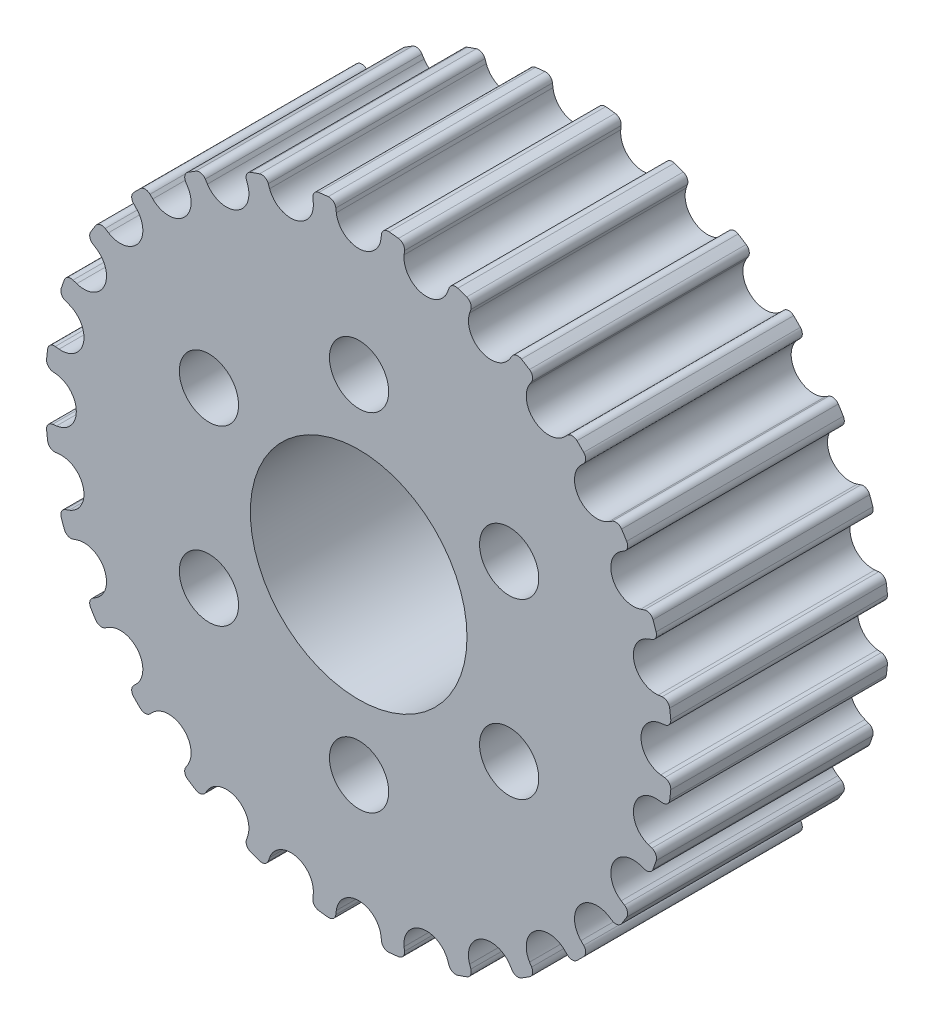
from build123d import *

# Parameters (mm, degrees)
SKETCH_1_R              = 7.5
EXTRUDE_1_DEPTH         = 15
HOLE_WIZARD_4_1_4_1_1_D = 4.1


with BuildPart() as part:
    # 草图1 → 凸台-拉伸1 (new body)
    with BuildSketch(Plane.XY):
        with BuildLine():
            Line((1.554033471, 21.184411781), (1.521048557, 20.915771216))
            ThreePointArc((1.521048557, 20.915771216), (-0.027323439, 19.545887392), (-1.575695436, 20.915771216))
            Line((-1.575695436, 20.915771216), (-1.608680349, 21.184411781))
            ThreePointArc((-1.608680349, 21.184411781), (-1.784864491, 21.500423691), (-2.131632272, 21.603653945))
            ThreePointArc((-2.131632272, 21.603653945), (-2.457848286, 21.569392044), (-2.783509374, 21.530205035))
            ThreePointArc((-2.783509374, 21.530205035), (-3.09861207, 21.352399889), (-3.200059642, 21.005106398))
            Line((-3.200059642, 21.005106398), (-3.172439406, 20.735861379))
            ThreePointArc((-3.172439406, 20.735861379), (-4.377162656, 19.055778219), (-6.191541562, 20.046771013))
            Line((-6.191541562, 20.046771013), (-6.283477625, 20.301336364))
            ThreePointArc((-6.283477625, 20.301336364), (-6.525563727, 20.570220536), (-6.886608208, 20.593699501))
            ThreePointArc((-6.886608208, 20.593699501), (-7.197021316, 20.487706726), (-7.505797471, 20.377035808))
            ThreePointArc((-7.505797471, 20.377035808), (-7.773434517, 20.133571662), (-7.795058515, 19.772411335))
            Line((-7.795058515, 19.772411335), (-7.708218122, 19.516062931))
            ThreePointArc((-7.708218122, 19.516062931), (-8.508882771, 17.610026822), (-10.498288052, 18.172436068))
            Line((-10.498288052, 18.172436068), (-10.644565205, 18.400161236))
            ThreePointArc((-10.644565205, 18.400161236), (-10.940414061, 18.608434695), (-11.297630964, 18.550985038))
            ThreePointArc((-11.297630964, 18.550985038), (-11.576675756, 18.378576309), (-11.853083652, 18.201970983))
            ThreePointArc((-11.853083652, 18.201970983), (-12.059834609, 17.905056146), (-12.000550715, 17.54813907))
            Line((-12.000550715, 17.54813907), (-11.858844707, 17.317541662))
            ThreePointArc((-11.858844707, 17.317541662), (-12.215302086, 15.281129211), (-14.279976653, 15.386753363))
            Line((-14.279976653, 15.386753363), (-14.47325995, 15.576219257))
            ThreePointArc((-14.47325995, 15.576219257), (-14.808036462, 15.713438301), (-15.14351344, 15.577940788))
            ThreePointArc((-15.14351344, 15.577940788), (-15.377197445, 15.347761398), (-15.607376836, 15.114077393))
            ThreePointArc((-15.607376836, 15.114077393), (-15.742874348, 14.778600415), (-15.605655304, 14.443823903))
            Line((-15.605655304, 14.443823903), (-15.41618941, 14.250540606))
            ThreePointArc((-15.41618941, 14.250540606), (-15.310565258, 12.185866039), (-17.346977709, 11.829408659))
            Line((-17.346977709, 11.829408659), (-17.577575117, 11.971114668))
            ThreePointArc((-17.577575117, 11.971114668), (-17.934492193, 12.030398562), (-18.23140703, 11.823647605))
            ThreePointArc((-18.23140703, 11.823647605), (-18.408012356, 11.547239709), (-18.580421086, 11.268194917))
            ThreePointArc((-18.580421086, 11.268194917), (-18.637870742, 10.910978014), (-18.429597284, 10.615129158))
            Line((-18.429597284, 10.615129158), (-18.201872116, 10.468852005))
            ThreePointArc((-18.201872116, 10.468852005), (-17.639462869, 8.479446724), (-19.545498979, 7.678782075))
            Line((-19.545498979, 7.678782075), (-19.801847382, 7.765622467))
            ThreePointArc((-19.801847382, 7.765622467), (-20.163007709, 7.74399847), (-20.406471855, 7.476361423))
            ThreePointArc((-20.406471855, 7.476361423), (-20.517142773, 7.167585269), (-20.623135549, 6.857172161))
            ThreePointArc((-20.623135549, 6.857172161), (-20.599656583, 6.49612768), (-20.330772412, 6.254041577))
            Line((-20.330772412, 6.254041577), (-20.07620706, 6.162105515))
            ThreePointArc((-20.07620706, 6.162105515), (-19.085214266, 4.347726609), (-20.765297426, 3.143003359))
            Line((-20.765297426, 3.143003359), (-21.034542445, 3.170623595))
            ThreePointArc((-21.034542445, 3.170623595), (-21.381835936, 3.069176023), (-21.559641082, 2.754073327))
            ThreePointArc((-21.559641082, 2.754073327), (-21.598828091, 2.428412239), (-21.633089992, 2.102196225))
            ThreePointArc((-21.633089992, 2.102196225), (-21.529859738, 1.755428444), (-21.213847828, 1.579244302))
            Line((-21.213847828, 1.579244302), (-20.945207263, 1.546259388))
            ThreePointArc((-20.945207263, 1.546259388), (-19.575323439, -0.002112608), (-20.945207263, -1.550484605))
            Line((-20.945207263, -1.550484605), (-21.213847828, -1.583469519))
            ThreePointArc((-21.213847828, -1.583469519), (-21.529859738, -1.75965366), (-21.633089992, -2.106421441))
            ThreePointArc((-21.633089992, -2.106421441), (-21.598828091, -2.432637455), (-21.559641082, -2.758298543))
            ThreePointArc((-21.559641082, -2.758298543), (-21.381835936, -3.073401239), (-21.034542445, -3.174848812))
            Line((-21.034542445, -3.174848812), (-20.765297426, -3.147228575))
            ThreePointArc((-20.765297426, -3.147228575), (-19.085214266, -4.351951825), (-20.07620706, -6.166330731))
            Line((-20.07620706, -6.166330731), (-20.330772412, -6.258266794))
            ThreePointArc((-20.330772412, -6.258266794), (-20.599656583, -6.500352897), (-20.623135549, -6.861397377))
            ThreePointArc((-20.623135549, -6.861397377), (-20.517142773, -7.171810485), (-20.406471855, -7.48058664))
            ThreePointArc((-20.406471855, -7.48058664), (-20.163007709, -7.748223686), (-19.801847382, -7.769847684))
            Line((-19.801847382, -7.769847684), (-19.545498979, -7.683007291))
            ThreePointArc((-19.545498979, -7.683007291), (-17.639462869, -8.48367194), (-18.201872116, -10.473077221))
            Line((-18.201872116, -10.473077221), (-18.429597284, -10.619354374))
            ThreePointArc((-18.429597284, -10.619354374), (-18.637870742, -10.91520323), (-18.580421086, -11.272420133))
            ThreePointArc((-18.580421086, -11.272420133), (-18.408012356, -11.551464925), (-18.23140703, -11.827872821))
            ThreePointArc((-18.23140703, -11.827872821), (-17.934492193, -12.034623778), (-17.577575117, -11.975339884))
            Line((-17.577575117, -11.975339884), (-17.346977709, -11.833633876))
            ThreePointArc((-17.346977709, -11.833633876), (-15.310565258, -12.190091255), (-15.41618941, -14.254765823))
            Line((-15.41618941, -14.254765823), (-15.605655304, -14.448049119))
            ThreePointArc((-15.605655304, -14.448049119), (-15.742874348, -14.782825631), (-15.607376836, -15.11830261))
            ThreePointArc((-15.607376836, -15.11830261), (-15.377197445, -15.351986614), (-15.14351344, -15.582166005))
            ThreePointArc((-15.14351344, -15.582166005), (-14.808036462, -15.717663517), (-14.47325995, -15.580444473))
            Line((-14.47325995, -15.580444473), (-14.279976653, -15.390978579))
            ThreePointArc((-14.279976653, -15.390978579), (-12.215302086, -15.285354427), (-11.858844707, -17.321766878))
            Line((-11.858844707, -17.321766878), (-12.000550715, -17.552364287))
            ThreePointArc((-12.000550715, -17.552364287), (-12.059834609, -17.909281362), (-11.853083652, -18.206196199))
            ThreePointArc((-11.853083652, -18.206196199), (-11.576675756, -18.382801525), (-11.297630964, -18.555210255))
            ThreePointArc((-11.297630964, -18.555210255), (-10.940414061, -18.612659911), (-10.644565205, -18.404386453))
            Line((-10.644565205, -18.404386453), (-10.498288052, -18.176661285))
            ThreePointArc((-10.498288052, -18.176661285), (-8.508882771, -17.614252038), (-7.708218122, -19.520288148))
            Line((-7.708218122, -19.520288148), (-7.795058515, -19.776636551))
            ThreePointArc((-7.795058515, -19.776636551), (-7.773434517, -20.137796878), (-7.505797471, -20.381261024))
            ThreePointArc((-7.505797471, -20.381261024), (-7.197021316, -20.491931943), (-6.886608208, -20.597924718))
            ThreePointArc((-6.886608208, -20.597924718), (-6.525563727, -20.574445752), (-6.283477625, -20.305561581))
            Line((-6.283477625, -20.305561581), (-6.191541562, -20.050996229))
            ThreePointArc((-6.191541562, -20.050996229), (-4.377162656, -19.060003436), (-3.172439406, -20.740086595))
            Line((-3.172439406, -20.740086595), (-3.200059642, -21.009331614))
            ThreePointArc((-3.200059642, -21.009331614), (-3.09861207, -21.356625105), (-2.783509374, -21.534430251))
            ThreePointArc((-2.783509374, -21.534430251), (-2.457848286, -21.573617261), (-2.131632272, -21.607879161))
            ThreePointArc((-2.131632272, -21.607879161), (-1.784864491, -21.504648907), (-1.608680349, -21.188636997))
            Line((-1.608680349, -21.188636997), (-1.575695436, -20.919996432))
            ThreePointArc((-1.575695436, -20.919996432), (-0.027323439, -19.550112608), (1.521048557, -20.919996432))
            Line((1.521048557, -20.919996432), (1.554033471, -21.188636997))
            ThreePointArc((1.554033471, -21.188636997), (1.730217613, -21.504648907), (2.076985394, -21.607879161))
            ThreePointArc((2.076985394, -21.607879161), (2.403201408, -21.573617261), (2.728862496, -21.534430251))
            ThreePointArc((2.728862496, -21.534430251), (3.043965192, -21.356625105), (3.145412764, -21.009331614))
            Line((3.145412764, -21.009331614), (3.117792528, -20.740086595))
            ThreePointArc((3.117792528, -20.740086595), (4.322515778, -19.060003436), (6.136894684, -20.050996229))
            Line((6.136894684, -20.050996229), (6.228830746, -20.305561581))
            ThreePointArc((6.228830746, -20.305561581), (6.470916849, -20.574445752), (6.83196133, -20.597924718))
            ThreePointArc((6.83196133, -20.597924718), (7.142374438, -20.491931943), (7.451150593, -20.381261024))
            ThreePointArc((7.451150593, -20.381261024), (7.718787639, -20.137796878), (7.740411637, -19.776636551))
            Line((7.740411637, -19.776636551), (7.653571244, -19.520288148))
            ThreePointArc((7.653571244, -19.520288148), (8.454235893, -17.614252038), (10.443641174, -18.176661285))
            Line((10.443641174, -18.176661285), (10.589918327, -18.404386453))
            ThreePointArc((10.589918327, -18.404386453), (10.885767183, -18.612659911), (11.242984086, -18.555210255))
            ThreePointArc((11.242984086, -18.555210255), (11.522028878, -18.382801525), (11.798436774, -18.206196199))
            ThreePointArc((11.798436774, -18.206196199), (12.005187731, -17.909281362), (11.945903837, -17.552364287))
            Line((11.945903837, -17.552364287), (11.804197828, -17.321766878))
            ThreePointArc((11.804197828, -17.321766878), (12.160655208, -15.285354427), (14.225329775, -15.390978579))
            Line((14.225329775, -15.390978579), (14.418613072, -15.580444473))
            ThreePointArc((14.418613072, -15.580444473), (14.753389584, -15.717663517), (15.088866562, -15.582166005))
            ThreePointArc((15.088866562, -15.582166005), (15.322550567, -15.351986614), (15.552729958, -15.11830261))
            ThreePointArc((15.552729958, -15.11830261), (15.68822747, -14.782825631), (15.551008426, -14.448049119))
            Line((15.551008426, -14.448049119), (15.361542532, -14.254765823))
            ThreePointArc((15.361542532, -14.254765823), (15.25591838, -12.190091255), (17.292330831, -11.833633876))
            Line((17.292330831, -11.833633876), (17.522928239, -11.975339884))
            ThreePointArc((17.522928239, -11.975339884), (17.879845315, -12.034623778), (18.176760152, -11.827872821))
            ThreePointArc((18.176760152, -11.827872821), (18.353365478, -11.551464925), (18.525774208, -11.272420133))
            ThreePointArc((18.525774208, -11.272420133), (18.583223864, -10.91520323), (18.374950406, -10.619354374))
            Line((18.374950406, -10.619354374), (18.147225238, -10.473077221))
            ThreePointArc((18.147225238, -10.473077221), (17.584815991, -8.48367194), (19.4908521, -7.683007291))
            Line((19.4908521, -7.683007291), (19.747200504, -7.769847684))
            ThreePointArc((19.747200504, -7.769847684), (20.108360831, -7.748223686), (20.351824977, -7.48058664))
            ThreePointArc((20.351824977, -7.48058664), (20.462495895, -7.171810485), (20.568488671, -6.861397377))
            ThreePointArc((20.568488671, -6.861397377), (20.545009705, -6.500352897), (20.276125534, -6.258266794))
            Line((20.276125534, -6.258266794), (20.021560182, -6.166330731))
            ThreePointArc((20.021560182, -6.166330731), (19.030567388, -4.351951825), (20.710650548, -3.147228575))
            Line((20.710650548, -3.147228575), (20.979895567, -3.174848812))
            ThreePointArc((20.979895567, -3.174848812), (21.327189058, -3.073401239), (21.504994204, -2.758298543))
            ThreePointArc((21.504994204, -2.758298543), (21.544181213, -2.432637455), (21.578443114, -2.106421441))
            ThreePointArc((21.578443114, -2.106421441), (21.47521286, -1.75965366), (21.15920095, -1.583469519))
            Line((21.15920095, -1.583469519), (20.890560385, -1.550484605))
            ThreePointArc((20.890560385, -1.550484605), (19.520676561, -0.002112608), (20.890560385, 1.546259388))
            Line((20.890560385, 1.546259388), (21.15920095, 1.579244302))
            ThreePointArc((21.15920095, 1.579244302), (21.47521286, 1.755428444), (21.578443114, 2.102196225))
            ThreePointArc((21.578443114, 2.102196225), (21.544181213, 2.428412239), (21.504994204, 2.754073327))
            ThreePointArc((21.504994204, 2.754073327), (21.327189058, 3.069176023), (20.979895567, 3.170623595))
            Line((20.979895567, 3.170623595), (20.710650548, 3.143003359))
            ThreePointArc((20.710650548, 3.143003359), (19.030567388, 4.347726609), (20.021560182, 6.162105515))
            Line((20.021560182, 6.162105515), (20.276125534, 6.254041577))
            ThreePointArc((20.276125534, 6.254041577), (20.545009705, 6.49612768), (20.568488671, 6.857172161))
            ThreePointArc((20.568488671, 6.857172161), (20.462495895, 7.167585269), (20.351824977, 7.476361423))
            ThreePointArc((20.351824977, 7.476361423), (20.108360831, 7.74399847), (19.747200504, 7.765622467))
            Line((19.747200504, 7.765622467), (19.4908521, 7.678782075))
            ThreePointArc((19.4908521, 7.678782075), (17.584815991, 8.479446724), (18.147225238, 10.468852005))
            Line((18.147225238, 10.468852005), (18.374950406, 10.615129158))
            ThreePointArc((18.374950406, 10.615129158), (18.583223864, 10.910978014), (18.525774208, 11.268194917))
            ThreePointArc((18.525774208, 11.268194917), (18.353365478, 11.547239709), (18.176760152, 11.823647605))
            ThreePointArc((18.176760152, 11.823647605), (17.879845315, 12.030398562), (17.522928239, 11.971114668))
            Line((17.522928239, 11.971114668), (17.292330831, 11.829408659))
            ThreePointArc((17.292330831, 11.829408659), (15.25591838, 12.185866039), (15.361542532, 14.250540606))
            Line((15.361542532, 14.250540606), (15.551008426, 14.443823903))
            ThreePointArc((15.551008426, 14.443823903), (15.68822747, 14.778600415), (15.552729958, 15.114077393))
            ThreePointArc((15.552729958, 15.114077393), (15.322550567, 15.347761398), (15.088866562, 15.577940788))
            ThreePointArc((15.088866562, 15.577940788), (14.753389584, 15.713438301), (14.418613072, 15.576219257))
            Line((14.418613072, 15.576219257), (14.225329775, 15.386753363))
            ThreePointArc((14.225329775, 15.386753363), (12.160655208, 15.281129211), (11.804197828, 17.317541662))
            Line((11.804197828, 17.317541662), (11.945903837, 17.54813907))
            ThreePointArc((11.945903837, 17.54813907), (12.005187731, 17.905056146), (11.798436774, 18.201970983))
            ThreePointArc((11.798436774, 18.201970983), (11.522028878, 18.378576309), (11.242984086, 18.550985038))
            ThreePointArc((11.242984086, 18.550985038), (10.885767183, 18.608434695), (10.589918327, 18.400161236))
            Line((10.589918327, 18.400161236), (10.443641174, 18.172436068))
            ThreePointArc((10.443641174, 18.172436068), (8.454235893, 17.610026822), (7.653571244, 19.516062931))
            Line((7.653571244, 19.516062931), (7.740411637, 19.772411335))
            ThreePointArc((7.740411637, 19.772411335), (7.718787639, 20.133571662), (7.451150593, 20.377035808))
            ThreePointArc((7.451150593, 20.377035808), (7.142374438, 20.487706726), (6.83196133, 20.593699501))
            ThreePointArc((6.83196133, 20.593699501), (6.470916849, 20.570220536), (6.228830746, 20.301336364))
            Line((6.228830746, 20.301336364), (6.136894684, 20.046771013))
            ThreePointArc((6.136894684, 20.046771013), (4.322515778, 19.055778219), (3.117792528, 20.735861379))
            Line((3.117792528, 20.735861379), (3.145412764, 21.005106398))
            ThreePointArc((3.145412764, 21.005106398), (3.043965192, 21.352399889), (2.728862496, 21.530205035))
            ThreePointArc((2.728862496, 21.530205035), (2.403201408, 21.569392044), (2.076985394, 21.603653945))
            ThreePointArc((2.076985394, 21.603653945), (1.730217613, 21.500423691), (1.554033471, 21.184411781))
        make_face()
        with Locations((-0.027323439, -0.002112608)):
            Circle(SKETCH_1_R, mode=Mode.SUBTRACT)
    extrude(amount=EXTRUDE_1_DEPTH)

    # Ø4.1 (4.1) 直径孔1 (through all)
    with Locations(Plane(origin=(0, 0, 0), x_dir=(-1, 0, 0), z_dir=(0, 0, -1))):
        with Locations((0, 12), (10.392304845, 6), (10.392304845, -6), (0, -12), (-10.392304845, -6), (-10.392304845, 6)):
            Hole(HOLE_WIZARD_4_1_4_1_1_D / 2)


solid = part.part
